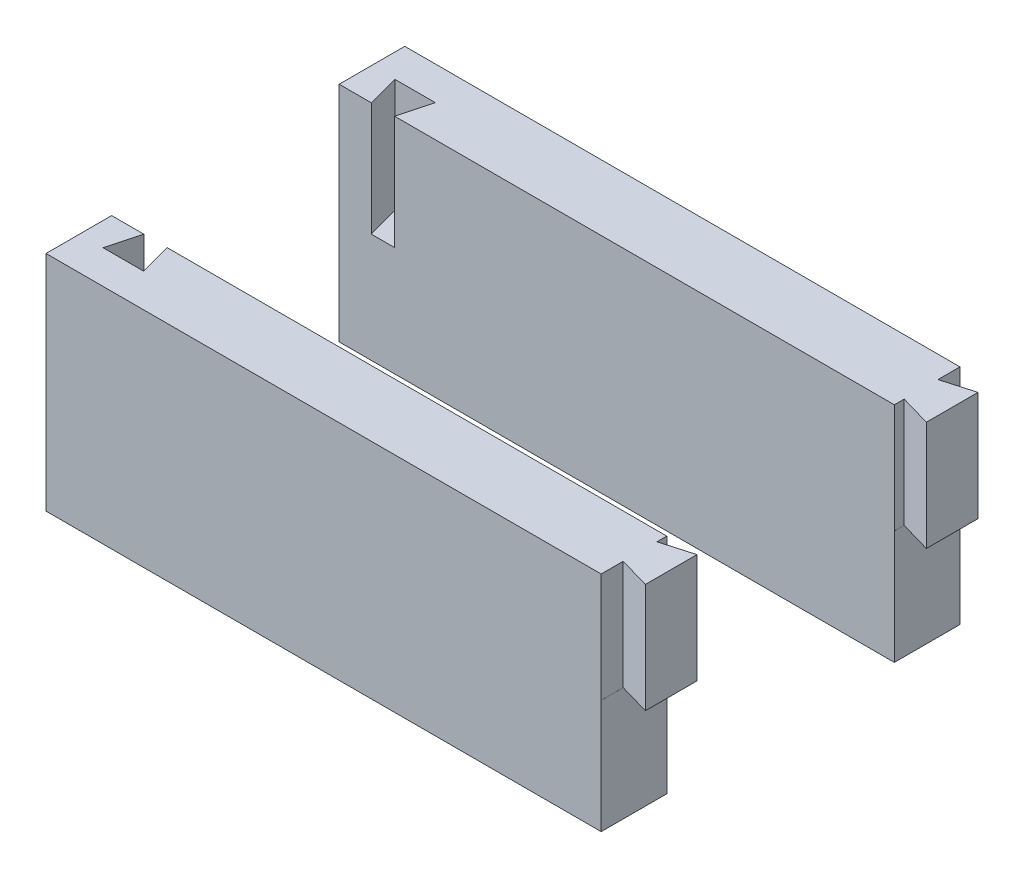
from build123d import *

# Parameters (mm, degrees)
SKETCH1_W               = 134
SKETCH1_H               = 51
BOSS_EXTRUDE1_DEPTH     = 15
CUT_EXTRUDE2_DEPTH      = 1
CUT_EXTRUDE2_DEPTH_BACK = 26
CUT_EXTRUDE4_DEPTH      = 25
SKETCH7_W               = 7.11
SKETCH7_H               = 15
CUT_EXTRUDE5_DEPTH      = 26


with BuildPart() as part:
    # Sketch1 → Boss-Extrude1 (new body)
    with BuildSketch(Plane.XY):
        with Locations((6.063380282, 3.112676056)):
            Rectangle(SKETCH1_W, SKETCH1_H)
    extrude(amount=BOSS_EXTRUDE1_DEPTH)

    # Sketch3 → Cut-Extrude2 (cut, two sides)
    with BuildSketch(Plane(origin=(0, 28.612676056, 0), x_dir=(1, 0, 0), z_dir=(0, 1, 0))) as cut_extrude2_sk:
        Polygon((-340.610496837, 0), (-60.936619718, 0), (-53.586619718, 0), (-55.553644461, -7.34103628), (-46.319594976, -7.34103628), (-48.286619718, 0), (-120.671545534, 270.144220847), (-554.437861933, 623.29672746), (-774.376813236, 353.152506613), align=None)
    extrude(amount=CUT_EXTRUDE2_DEPTH, mode=Mode.SUBTRACT)
    extrude(cut_extrude2_sk.sketch, amount=-CUT_EXTRUDE2_DEPTH_BACK, mode=Mode.SUBTRACT)

    # Sketch5 → Cut-Extrude4 (cut)
    with BuildSketch(Plane(origin=(0, 28.612676056, 0), x_dir=(1, 0, 0), z_dir=(0, 1, 0))):
        Polygon((65.950043732, 0), (73.063380282, 0), (73.063380282, -0.210283567), (65.950043732, -2.25), align=None)
        Polygon((65.950043732, -15), (65.950043732, -9.970567134), (73.063380282, -12.010283567), (73.063380282, -15), align=None)
    extrude(amount=-CUT_EXTRUDE4_DEPTH, mode=Mode.SUBTRACT)

    # Sketch7 → Cut-Extrude5 (cut)
    with BuildSketch(Plane.XZ.offset(22.387323944)):
        with Locations((69.508380282, 7.5)):
            Rectangle(SKETCH7_W, SKETCH7_H)
    extrude(amount=-CUT_EXTRUDE5_DEPTH, mode=Mode.SUBTRACT)


with BuildPart() as body_2:
    # Mirror2: mirrored copy
    add(part.part.mirror(Plane(origin=(0, 0, -26), x_dir=(1, 0, 0), z_dir=(0, 0, -1))))


solid = Compound([part.part, body_2.part])
